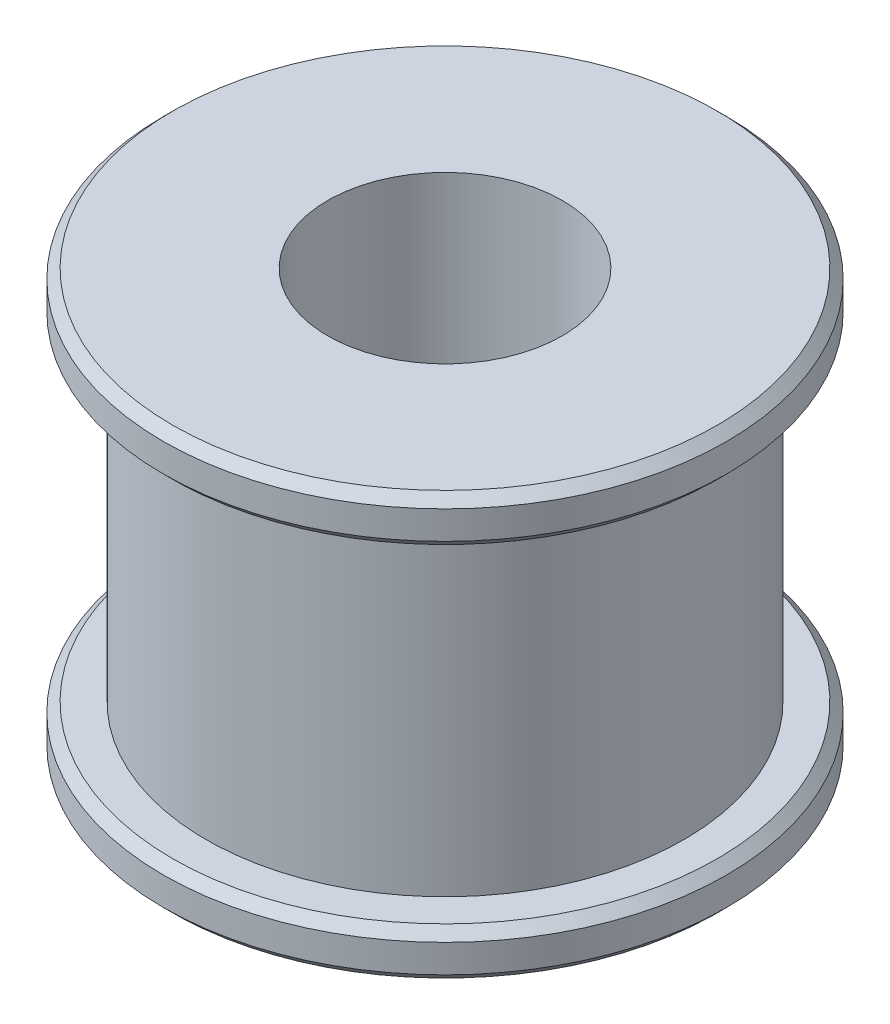
from build123d import *

# Parameters (mm, degrees)
CHAMFER1_SIZE = 0.2


with BuildPart() as part:
    # Sketch1 → Revolve1 (revolve)
    with BuildSketch(Plane.XY):
        Polygon((2.5, 0), (2.5, 9), (6, 9), (6, 8), (5.092958179, 8), (5.092958179, 1), (6, 1), (6, 0), align=None)
    revolve(axis=Axis((0, 0, 0), (0, 1, 0)))

    # Chamfer1
    chamfer1_edges = [part.edges().sort_by_distance(p)[0] for p in [
        (-6, 0, 0),
        (-6, 1, 0),
        (-6, 8, 0),
        (-6, 9, 0),
    ]]
    chamfer(chamfer1_edges, length=CHAMFER1_SIZE)


solid = part.part
